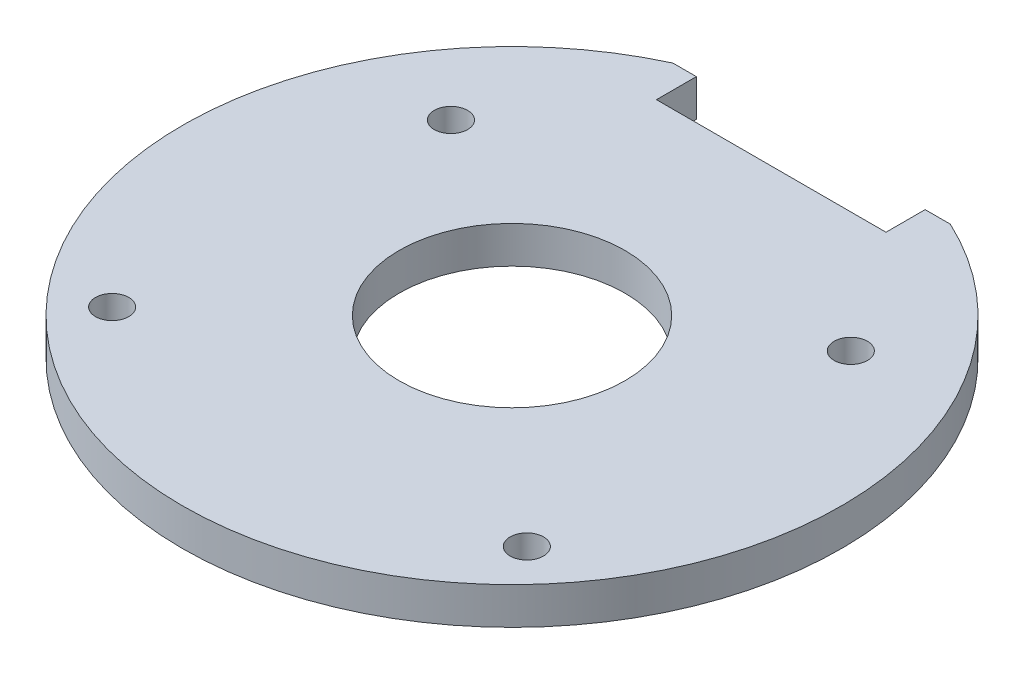
from build123d import *

# Parameters (mm, degrees)
SKETCH_2_R      = 15.25
SKETCH_2_R_2    = 2.25
EXTRUDE_1_DEPTH = 5


with BuildPart() as part:
    # Эскиз2 → Бобышка-Вытянуть1 (new body)
    with BuildSketch(Plane(origin=(0, 0, 0), x_dir=(1, 0, 0), z_dir=(0, 1, 0))):
        with BuildLine():
            Line((-15.5, 35), (15.5, 35))
            Line((15.5, 35), (15.5, 40.286336603))
            Line((15.5, 40.286336603), (18.901351356, 40.286336603))
            ThreePointArc((18.901351356, 40.286336603), (-0.126903456, -44.49981905), (-18.671270685, 40.393485254))
            Line((-18.671270685, 40.393485254), (-15.5, 40.393485254))
            Line((-15.5, 40.393485254), (-15.5, 35))
        make_face()
        Circle(SKETCH_2_R, mode=Mode.SUBTRACT)
        with Locations((-27, 18.75)):
            Circle(SKETCH_2_R_2, mode=Mode.SUBTRACT)
        with Locations((27, 18.75)):
            Circle(SKETCH_2_R_2, mode=Mode.SUBTRACT)
        with Locations((28, -26)):
            Circle(SKETCH_2_R_2, mode=Mode.SUBTRACT)
        with Locations((-28, -26)):
            Circle(SKETCH_2_R_2, mode=Mode.SUBTRACT)
    extrude(amount=EXTRUDE_1_DEPTH)


solid = part.part
